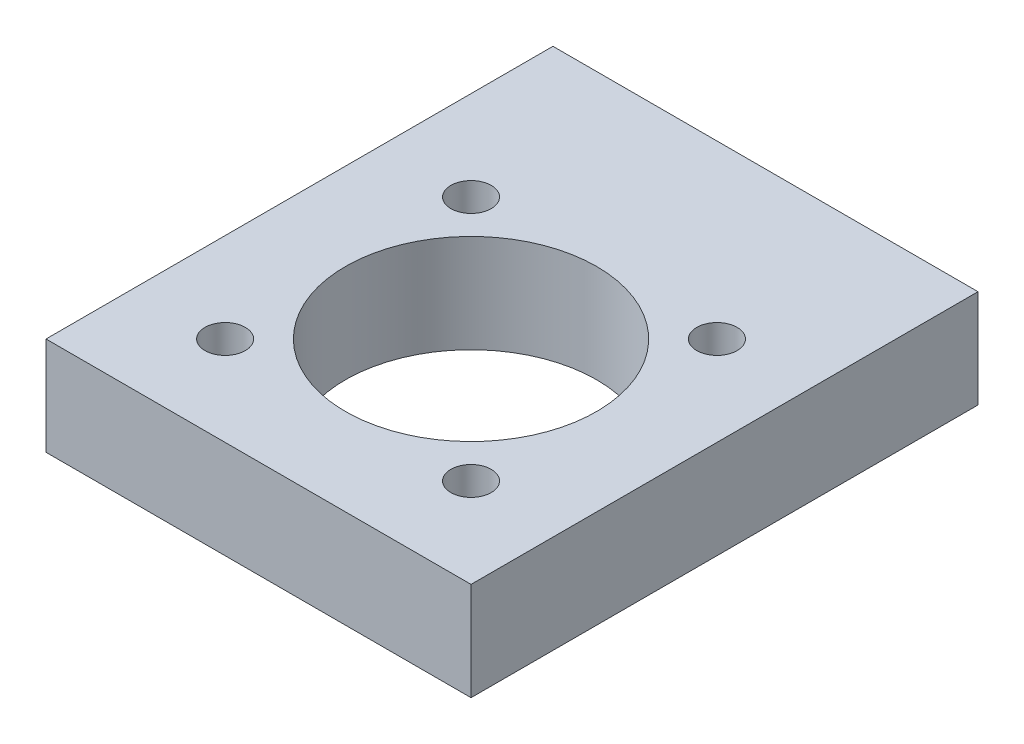
from build123d import *

# Parameters (mm, degrees)
BOSS_EXTRUDE1_DEPTH = 12.7
CUT_EXTRUDE1_REACH  = 14.7
SKETCH1_R           = 2.60985
CUT_EXTRUDE2_REACH  = 14.7
SKETCH3_R           = 16.256
SKETCH5_R           = 2.0193
CUT_EXTRUDE3_DEPTH  = 12.7


with BuildPart() as part:
    # Sketch2 → Boss-Extrude1 (new body)
    with BuildSketch(Plane(origin=(0, 0, 0), x_dir=(1, 0, 0), z_dir=(0, 1, 0))):
        Polygon((-27.5, 0), (-27.5, 38.1), (27.5, 38.1), (27.5, 0), (27.5, -27.5), (-27.5, -27.5), align=None)
    extrude(amount=BOSS_EXTRUDE1_DEPTH)

    # Sketch1 → Cut-Extrude1 (cut, up to next)
    with BuildSketch(Plane(origin=(0, 0, 0), x_dir=(1, 0, 0), z_dir=(0, 1, 0)), mode=Mode.PRIVATE) as cut_extrude1_sk1:
        with Locations((15.909902577, 15.909902577)):
            Circle(SKETCH1_R)
    cut_extrude1_tool1 = extrude(cut_extrude1_sk1.sketch, amount=CUT_EXTRUDE1_REACH, mode=Mode.PRIVATE) & part.part
    add(cut_extrude1_tool1.solids().sort_by_distance((15.909903, 0, -15.909903))[0], mode=Mode.SUBTRACT)
    # Sketch1 → Cut-Extrude1 (cut, up to next)
    with BuildSketch(Plane(origin=(0, 0, 0), x_dir=(1, 0, 0), z_dir=(0, 1, 0)), mode=Mode.PRIVATE) as cut_extrude1_sk2:
        with Locations((-15.909902577, 15.909902577)):
            Circle(SKETCH1_R)
    cut_extrude1_tool2 = extrude(cut_extrude1_sk2.sketch, amount=CUT_EXTRUDE1_REACH, mode=Mode.PRIVATE) & part.part
    add(cut_extrude1_tool2.solids().sort_by_distance((-15.909903, 0, -15.909903))[0], mode=Mode.SUBTRACT)
    # Sketch1 → Cut-Extrude1 (cut, up to next)
    with BuildSketch(Plane(origin=(0, 0, 0), x_dir=(1, 0, 0), z_dir=(0, 1, 0)), mode=Mode.PRIVATE) as cut_extrude1_sk3:
        with Locations((15.909902577, -15.909902577)):
            Circle(SKETCH1_R)
    cut_extrude1_tool3 = extrude(cut_extrude1_sk3.sketch, amount=CUT_EXTRUDE1_REACH, mode=Mode.PRIVATE) & part.part
    add(cut_extrude1_tool3.solids().sort_by_distance((15.909903, 0, 15.909903))[0], mode=Mode.SUBTRACT)
    # Sketch1 → Cut-Extrude1 (cut, up to next)
    with BuildSketch(Plane(origin=(0, 0, 0), x_dir=(1, 0, 0), z_dir=(0, 1, 0)), mode=Mode.PRIVATE) as cut_extrude1_sk4:
        with Locations((-15.909902577, -15.909902577)):
            Circle(SKETCH1_R)
    cut_extrude1_tool4 = extrude(cut_extrude1_sk4.sketch, amount=CUT_EXTRUDE1_REACH, mode=Mode.PRIVATE) & part.part
    add(cut_extrude1_tool4.solids().sort_by_distance((-15.909903, 0, 15.909903))[0], mode=Mode.SUBTRACT)

    # Sketch3 → Cut-Extrude2 (cut, up to next)
    with BuildSketch(Plane.XZ, mode=Mode.PRIVATE) as cut_extrude2_sk1:
        Circle(SKETCH3_R)
    cut_extrude2_tool1 = extrude(cut_extrude2_sk1.sketch, amount=-CUT_EXTRUDE2_REACH, mode=Mode.PRIVATE) & part.part
    add(cut_extrude2_tool1.solids().sort_by_distance((0, 0, 0))[0], mode=Mode.SUBTRACT)

    # Sketch5 → Cut-Extrude3 (cut)
    with BuildSketch(Plane(origin=(0, 0, -38.1), x_dir=(-1, 0, 0), z_dir=(0, 0, -1))):
        with Locations((6.35, 6.35)):
            Circle(SKETCH5_R)
        with Locations((19.05, 6.35)):
            Circle(SKETCH5_R)
        with Locations((-19.05, 6.35)):
            Circle(SKETCH5_R)
        with Locations((-6.35, 6.35)):
            Circle(SKETCH5_R)
    extrude(amount=-CUT_EXTRUDE3_DEPTH, mode=Mode.SUBTRACT)


solid = part.part
